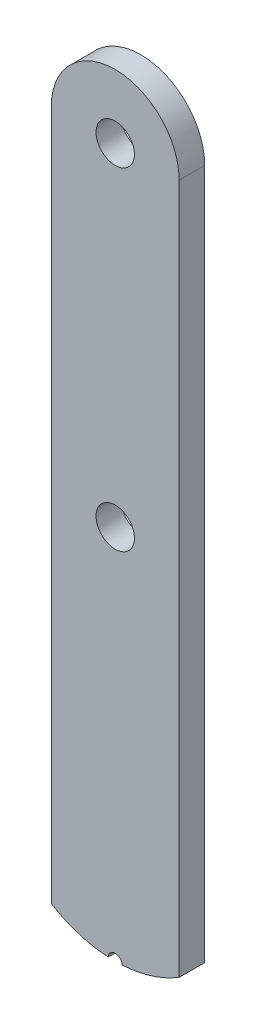
from build123d import *

# Parameters (mm, degrees)
SKETCH1_R           = 1.5
BOSS_EXTRUDE1_DEPTH = 2
SKETCH2_R           = 0.550401242
CUT_EXTRUDE1_DEPTH  = 10


with BuildPart() as part:
    # Sketch1 → Boss-Extrude1 (new body)
    with BuildSketch(Plane.XY):
        with BuildLine():
            Line((-5, 24.5), (-5, -29.5))
            ThreePointArc((-5, -29.5), (0, -30.913706536), (5, -29.5))
            Line((5, -29.5), (5, 24.5))
            ThreePointArc((5, 24.5), (0, 29.5), (-5, 24.5))
        make_face()
        with Locations((0, 24.5)):
            Circle(SKETCH1_R, mode=Mode.SUBTRACT)
        with Locations((0, -1.5)):
            Circle(SKETCH1_R, mode=Mode.SUBTRACT)
    extrude(amount=BOSS_EXTRUDE1_DEPTH)

    # Sketch2 → Cut-Extrude1 (cut)
    with BuildSketch(Plane.XY.offset(2)):
        with Locations((0, -30.913706536)):
            Circle(SKETCH2_R)
    extrude(amount=-CUT_EXTRUDE1_DEPTH, mode=Mode.SUBTRACT)


solid = part.part
